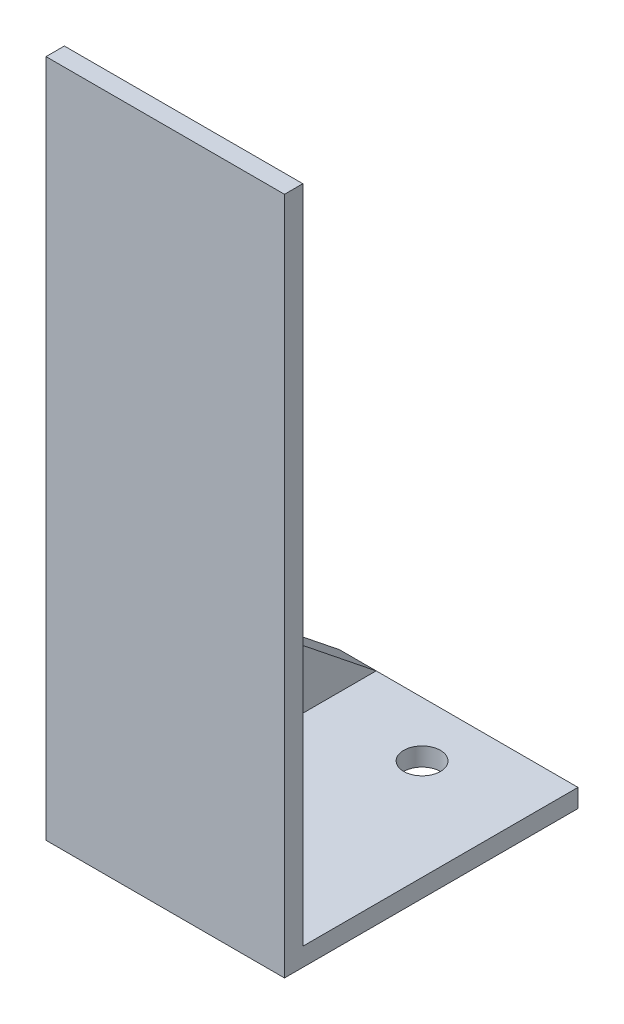
from build123d import *

# Parameters (mm, degrees)
BOSS_EXTRUDE1_DEPTH = 146.05
SKETCH2_W           = 63.5
SKETCH2_H           = 234.95
CUT_EXTRUDE1_DEPTH  = 146.05
BOSS_EXTRUDE2_DEPTH = 12.7
SKETCH4_R           = 6.35
CUT_EXTRUDE2_DEPTH  = 12.7


with BuildPart() as part:
    # Sketch1 → Boss-Extrude1 (new body)
    with BuildSketch(Plane(origin=(0, 0, 0), x_dir=(0, 0, -1), z_dir=(1, 0, 0))):
        Polygon((0, 0), (-101.6, 0), (-101.6, 6.35), (-101.6, 234.95), (-95.25, 234.95), (-95.25, 6.35), (0, 6.35), align=None)
    extrude(amount=BOSS_EXTRUDE1_DEPTH)

    # Sketch2 → Cut-Extrude1 (cut)
    with BuildSketch(Plane.XY.offset(101.6)):
        with Locations((31.75, 117.475)):
            Rectangle(SKETCH2_W, SKETCH2_H)
    extrude(amount=-CUT_EXTRUDE1_DEPTH, mode=Mode.SUBTRACT)

    # Sketch3 → Boss-Extrude2 (add)
    with BuildSketch(Plane.ZY.offset(-63.5)):
        Polygon((0, 6.35), (95.25, 82.55), (95.25, 6.35), align=None)
    extrude(amount=-BOSS_EXTRUDE2_DEPTH)

    # Sketch4 → Cut-Extrude2 (cut)
    with BuildSketch(Plane(origin=(0, 6.35, 0), x_dir=(1, 0, 0), z_dir=(0, 1, 0))):
        with Locations((111.125, -19.05)):
            Circle(SKETCH4_R)
        with Locations((111.125, -82.55)):
            Circle(SKETCH4_R)
    extrude(amount=-CUT_EXTRUDE2_DEPTH, mode=Mode.SUBTRACT)


solid = part.part
